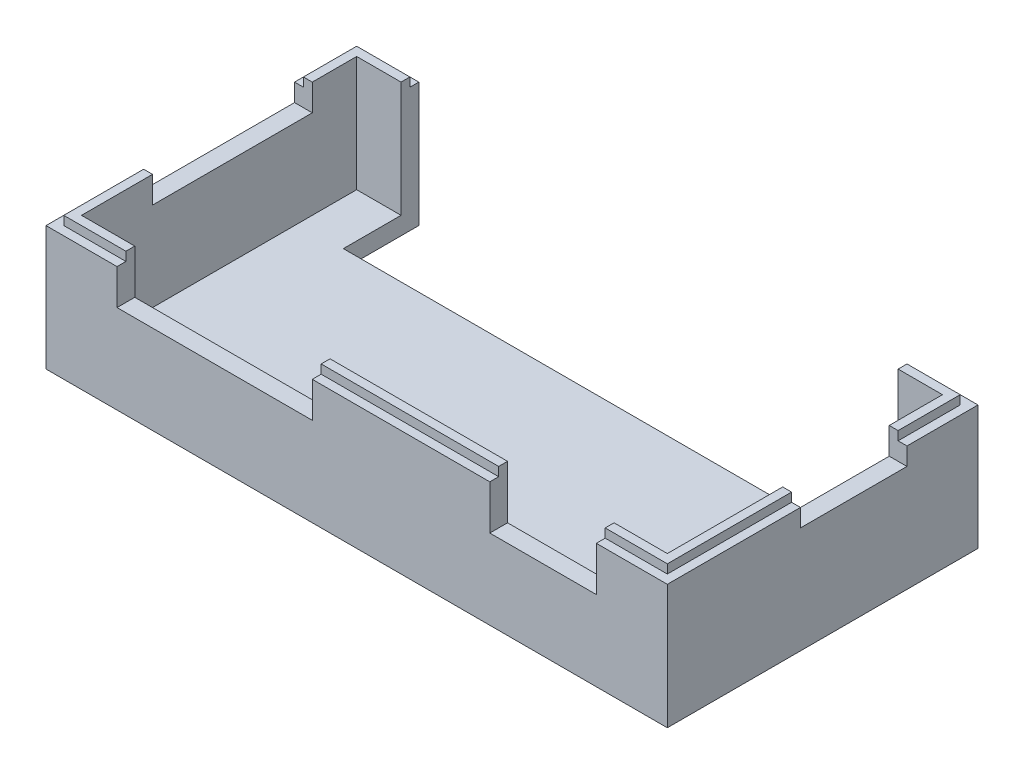
from build123d import *

# Parameters (mm, degrees)
SKETCH1_W               = 70
SKETCH1_H               = 35
BOSS_EXTRUDE1_DEPTH     = 2
SKETCH2_W               = 70
SKETCH2_H               = 35
SKETCH2_W_2             = 66
SKETCH2_H_2             = 31
BOSS_EXTRUDE2_DEPTH     = 12
SKETCH3_W               = 56
SKETCH3_H               = 8.5
CUT_EXTRUDE1_DEPTH      = 17
CUT_EXTRUDE1_DEPTH_BACK = 15
SKETCH4_W               = 12
SKETCH4_H               = 2
CUT_EXTRUDE2_DEPTH      = 17
SKETCH5_W               = 9
SKETCH5_H               = 4
SKETCH5_W_2             = 12
SKETCH5_H_2             = 5
CUT_EXTRUDE3_DEPTH      = 17
SKETCH6_W               = 18
SKETCH6_H               = 2
CUT_EXTRUDE4_DEPTH      = 17
SKETCH7_W               = 4
SKETCH7_H               = 1
SKETCH7_W_2             = 20
BOSS_EXTRUDE4_DEPTH     = 1
SKETCH8_W               = 4
SKETCH8_H               = 5
CUT_EXTRUDE5_DEPTH      = 3


with BuildPart() as part:
    # Sketch1 → Boss-Extrude1 (new body)
    with BuildSketch(Plane(origin=(0, 0, 0), x_dir=(1, 0, 0), z_dir=(0, 1, 0))):
        with Locations((35, 17.5)):
            Rectangle(SKETCH1_W, SKETCH1_H)
    extrude(amount=BOSS_EXTRUDE1_DEPTH)

    # Sketch2 → Boss-Extrude2 (add)
    with BuildSketch(Plane(origin=(0, 2, 0), x_dir=(1, 0, 0), z_dir=(0, 1, 0))):
        with Locations((35, 17.5)):
            Rectangle(SKETCH2_W, SKETCH2_H)
        with Locations((35, 17.5)):
            Rectangle(SKETCH2_W_2, SKETCH2_H_2, mode=Mode.SUBTRACT)
    extrude(amount=BOSS_EXTRUDE2_DEPTH)

    # Sketch3 → Cut-Extrude1 (cut, two sides)
    with BuildSketch(Plane(origin=(0, 2, 0), x_dir=(1, 0, 0), z_dir=(0, 1, 0))) as cut_extrude1_sk:
        with Locations((35, 30.75)):
            Rectangle(SKETCH3_W, SKETCH3_H)
    extrude(amount=CUT_EXTRUDE1_DEPTH, mode=Mode.SUBTRACT)
    extrude(cut_extrude1_sk.sketch, amount=-CUT_EXTRUDE1_DEPTH_BACK, mode=Mode.SUBTRACT)

    # Sketch4 → Cut-Extrude2 (cut)
    with BuildSketch(Plane.ZY.offset(-68)):
        with Locations((-21, 13)):
            Rectangle(SKETCH4_W, SKETCH4_H)
    extrude(amount=-CUT_EXTRUDE2_DEPTH, mode=Mode.SUBTRACT)

    # Sketch5 → Cut-Extrude3 (cut)
    with BuildSketch(Plane(origin=(0, 0, -2), x_dir=(-1, 0, 0), z_dir=(0, 0, -1))):
        with Locations((-12.5, 12)):
            Rectangle(SKETCH5_W, SKETCH5_H)
        with Locations((-25.5, 12)):
            Rectangle(SKETCH5_W, SKETCH5_H)
        with Locations((-56, 11.5)):
            Rectangle(SKETCH5_W_2, SKETCH5_H_2)
    extrude(amount=-CUT_EXTRUDE3_DEPTH, mode=Mode.SUBTRACT)

    # Sketch6 → Cut-Extrude4 (cut)
    with BuildSketch(Plane(origin=(2, 0, 0), x_dir=(0, 0, -1), z_dir=(1, 0, 0))):
        with Locations((19, 13)):
            Rectangle(SKETCH6_W, SKETCH6_H)
    extrude(amount=-CUT_EXTRUDE4_DEPTH, mode=Mode.SUBTRACT)

    # Sketch7 → Boss-Extrude4 (add)
    with BuildSketch(Plane(origin=(0, 14, 0), x_dir=(1, 0, 0), z_dir=(0, 1, 0))):
        Polygon((7, 33), (7, 34), (1, 34), (1, 28), (2, 28), (2, 33), align=None)
        Polygon((2, 10), (1, 10), (1, 1), (8, 1), (8, 2), (2, 2), align=None)
        with Locations((19, 1.5)):
            Rectangle(SKETCH7_W, SKETCH7_H)
        with Locations((40, 1.5)):
            Rectangle(SKETCH7_W_2, SKETCH7_H)
        Polygon((69, 1), (69, 15), (68, 15), (68, 2), (62, 2), (62, 1), align=None)
        Polygon((68, 27), (69, 27), (69, 34), (63, 34), (63, 33), (68, 33), align=None)
    extrude(amount=BOSS_EXTRUDE4_DEPTH)

    # Sketch8 → Cut-Extrude5 (cut)
    with BuildSketch(Plane(origin=(0, 0, -2), x_dir=(-1, 0, 0), z_dir=(0, 0, -1))):
        with Locations((-19, 12.5)):
            Rectangle(SKETCH8_W, SKETCH8_H)
    extrude(amount=-CUT_EXTRUDE5_DEPTH, mode=Mode.SUBTRACT)


solid = part.part
